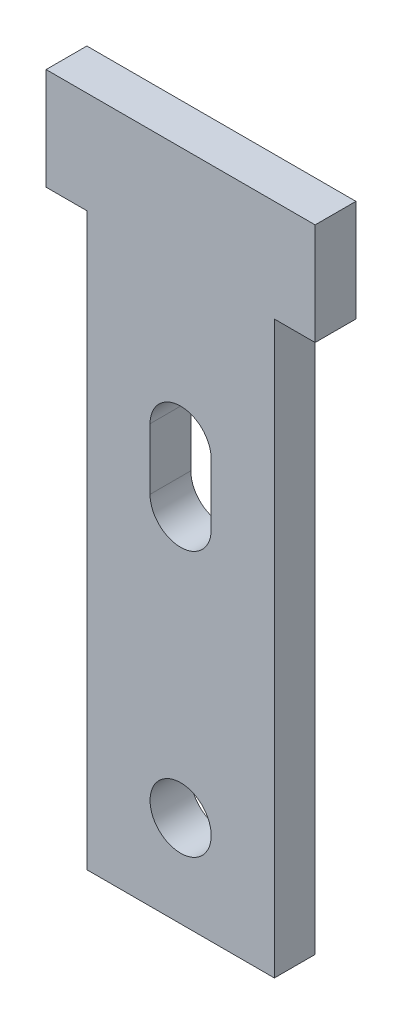
from build123d import *

# Parameters (mm, degrees)
SKETCH1_W           = 11.684
SKETCH1_H           = 2.54
BOSS_EXTRUDE1_DEPTH = 35.56
BOSS_EXTRUDE2_DEPTH = 2.54
CUT_EXTRUDE1_REACH  = 4.54
SKETCH3_R           = 1.905


with BuildPart() as part:
    # Sketch1 → Boss-Extrude1 (new body)
    with BuildSketch(Plane(origin=(0, 0, 0), x_dir=(1, 0, 0), z_dir=(0, 1, 0))):
        Rectangle(SKETCH1_W, SKETCH1_H)
    extrude(amount=BOSS_EXTRUDE1_DEPTH)

    # Sketch2 → Boss-Extrude2 (add)
    with BuildSketch(Plane.XY.offset(1.27)):
        Polygon((-8.382, 35.56), (-5.842, 35.56), (5.842, 35.56), (8.382, 35.56), (8.382, 41.91), (-8.382, 41.91), align=None)
    extrude(amount=-BOSS_EXTRUDE2_DEPTH)

    # Sketch3 → Cut-Extrude1 (cut, up to next)
    with BuildSketch(Plane.XY.offset(1.27), mode=Mode.PRIVATE) as cut_extrude1_sk1:
        with Locations((0, 5.715)):
            Circle(SKETCH3_R)
    cut_extrude1_tool1 = extrude(cut_extrude1_sk1.sketch, amount=-CUT_EXTRUDE1_REACH, mode=Mode.PRIVATE) & part.part
    add(cut_extrude1_tool1.solids().sort_by_distance((0, 5.715, 1.27))[0], mode=Mode.SUBTRACT)
    # Sketch3 → Cut-Extrude1 (cut, up to next)
    with BuildSketch(Plane.XY.offset(1.27), mode=Mode.PRIVATE) as cut_extrude1_sk2:
        with BuildLine():
            Line((1.905, 26.035), (1.905, 22.225))
            ThreePointArc((1.905, 22.225), (0, 20.32), (-1.905, 22.225))
            Line((-1.905, 22.225), (-1.905, 26.035))
            ThreePointArc((-1.905, 26.035), (0, 27.94), (1.905, 26.035))
        make_face()
    cut_extrude1_tool2 = extrude(cut_extrude1_sk2.sketch, amount=-CUT_EXTRUDE1_REACH, mode=Mode.PRIVATE) & part.part
    add(cut_extrude1_tool2.solids().sort_by_distance((0, 24.13, 1.27))[0], mode=Mode.SUBTRACT)


solid = part.part
